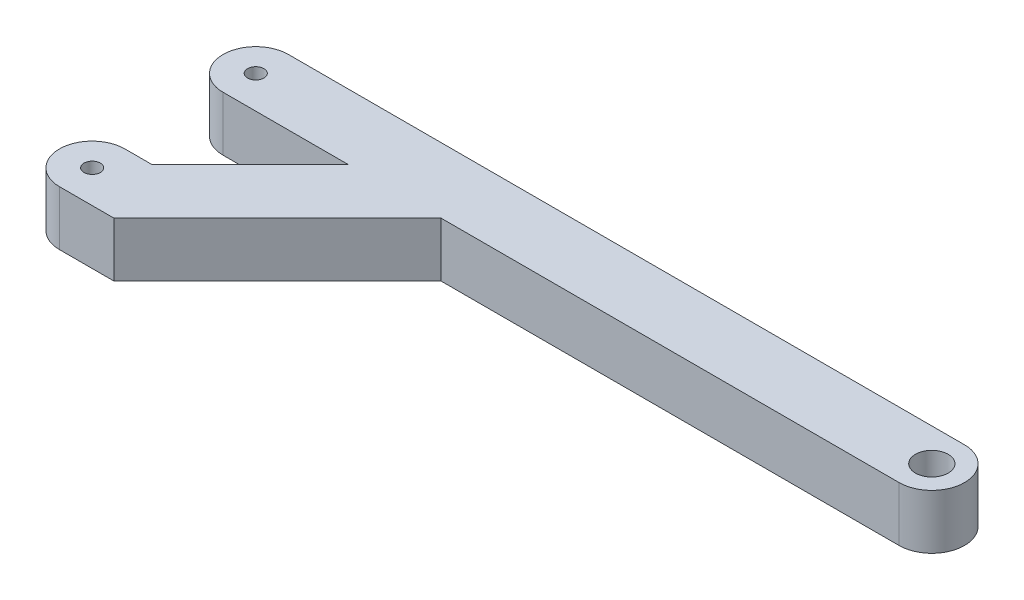
from build123d import *

# Parameters (mm, degrees)
SKETCH1_R           = 3
SKETCH1_R_2         = 1.5
BOSS_EXTRUDE1_DEPTH = 10
SKETCH2_R           = 1.5
BOSS_EXTRUDE2_DEPTH = 10


with BuildPart() as part:
    # Sketch1 → Boss-Extrude1 (new body)
    with BuildSketch(Plane(origin=(0, 0, 0), x_dir=(1, 0, 0), z_dir=(0, 1, 0))):
        with BuildLine():
            Line((0, -6), (-124, -6))
            ThreePointArc((-124, -6), (-130, 0), (-124, 6))
            Line((-124, 6), (0, 6))
            ThreePointArc((0, 6), (6, 0), (0, -6))
        make_face()
        Circle(SKETCH1_R, mode=Mode.SUBTRACT)
        with Locations((-124, 0)):
            Circle(SKETCH1_R_2, mode=Mode.SUBTRACT)
    extrude(amount=BOSS_EXTRUDE1_DEPTH)

    # Sketch2 → Boss-Extrude2 (add)
    with BuildSketch(Plane(origin=(0, 10, 0), x_dir=(1, 0, 0), z_dir=(0, 1, 0))):
        with BuildLine():
            Line((-119, -24), (-124, -24))
            ThreePointArc((-124, -24), (-130, -30), (-124, -36))
            Line((-124, -36), (-114, -36))
            Line((-114, -36), (-84, -6))
            Line((-84, -6), (-101, -6))
            Line((-101, -6), (-119, -24))
        make_face()
        with Locations((-124, -30)):
            Circle(SKETCH2_R, mode=Mode.SUBTRACT)
    extrude(amount=-BOSS_EXTRUDE2_DEPTH)


solid = part.part
